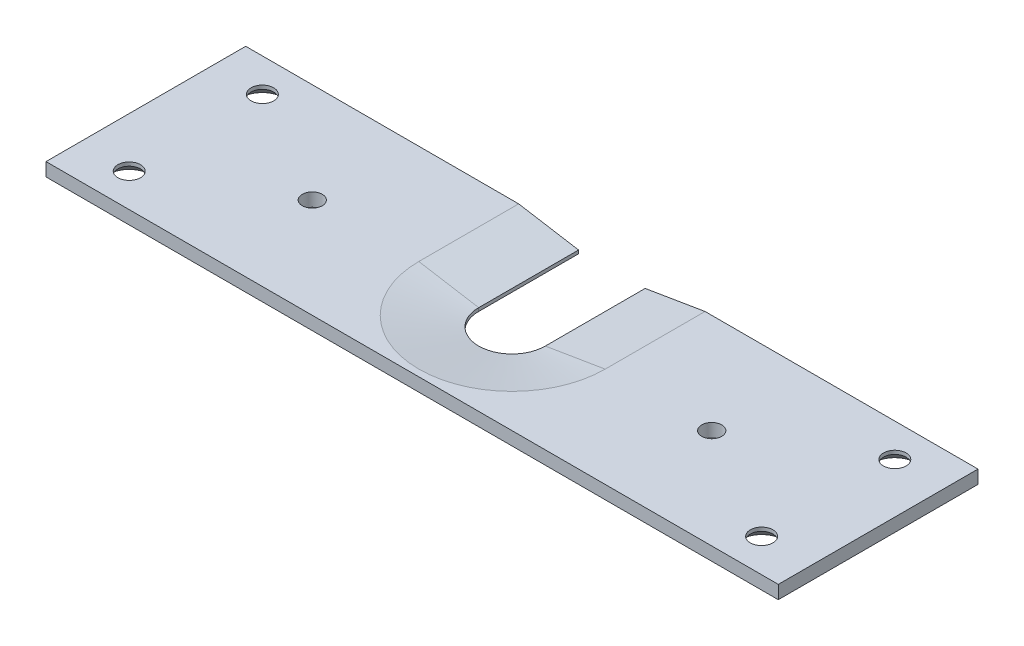
from build123d import *

# Parameters (mm, degrees)
SKETCH1_W                                    = 110
SKETCH1_H                                    = 30
EXTRUDE1_DEPTH                               = 2
CUT_EXTRUDE1_DEPTH                           = 3
CHAMFER1_SIZE                                = 9
CHAMFER1_SIZE2                               = 1.5
CSK_FOR_M3_COUNTERSUNK_RAISED_HEAD_S_2_COUNT = 2
CSK_FOR_M3_COUNTERSUNK_RAISED_HEAD_S_2_PITCH = 95
CSK_FOR_M3_COUNTERSUNK_RAISED_HEAD_S_3_COUNT = 2
CSK_FOR_M3_COUNTERSUNK_RAISED_HEAD_S_3_PITCH = 97.082439195
CSK_FOR_M3_COUNTERSUNK_RAISED_HEAD_S_4_COUNT = 2
CSK_FOR_M3_COUNTERSUNK_RAISED_HEAD_S_4_PITCH = 20
M3_TAPPED_HOLE1_D                            = 3


with BuildPart() as part:
    # Sketch1 → Extrude1 (new body)
    with BuildSketch(Plane(origin=(0, 0, 0), x_dir=(1, 0, 0), z_dir=(0, 1, 0))):
        Rectangle(SKETCH1_W, SKETCH1_H)
    extrude(amount=EXTRUDE1_DEPTH)

    # Sketch2 → Cut-Extrude1 (cut, through all)
    with BuildSketch(Plane(origin=(0, 2, 0), x_dir=(-1, 0, 0), z_dir=(0, 1, 0))):
        with BuildLine():
            Line((5, 0), (5, -15))
            Line((5, -15), (-5, -15))
            Line((-5, -15), (-5, 0))
            ThreePointArc((-5, 0), (0, 5), (5, 0))
        make_face()
    extrude(amount=-CUT_EXTRUDE1_DEPTH, mode=Mode.SUBTRACT)

    # Chamfer1
    chamfer1_edges = [part.edges().sort_by_distance(p)[0] for p in [
        (0, 2, 5),
        (5, 2, -7.5),
        (-5, 2, -7.5),
    ]]
    chamfer1_side = [part.faces().sort_by_distance(p)[0] for p in [
        (-53.859824575, 2, 0),
    ]]
    chamfer(chamfer1_edges, length=CHAMFER1_SIZE, length2=CHAMFER1_SIZE2, reference=chamfer1_side[0])

    # Sketch8 → CSK for M3 Countersunk Raised Head Screw1 (revolve, cut)
    with BuildSketch(Plane(origin=(47.5, 0, -10), x_dir=(0, 0, -1), z_dir=(1, 0, 0))):
        Polygon((0, 0), (0, 2), (1.7, 2), (1.7, 1.45), (3.15, 0), align=None)
    csk_for_m3_countersunk_raised_head_screw = revolve(axis=Axis((47.5, -6.35, -10), (0, 1, 0)), mode=Mode.SUBTRACT)

    # CSK for M3 Countersunk Raised Head S 2: CSK for M3 Countersunk Raised Head Screw1 ×2
    with Locations(*[(-i * CSK_FOR_M3_COUNTERSUNK_RAISED_HEAD_S_2_PITCH, 0, 0) for i in range(1, CSK_FOR_M3_COUNTERSUNK_RAISED_HEAD_S_2_COUNT)]):
        add(csk_for_m3_countersunk_raised_head_screw, mode=Mode.SUBTRACT)

    # CSK for M3 Countersunk Raised Head S 3: CSK for M3 Countersunk Raised Head Screw1 ×2
    with Locations(*[Vector(-0.978549785, 0, 0.206010481) * (i * CSK_FOR_M3_COUNTERSUNK_RAISED_HEAD_S_3_PITCH) for i in range(1, CSK_FOR_M3_COUNTERSUNK_RAISED_HEAD_S_3_COUNT)]):
        add(csk_for_m3_countersunk_raised_head_screw, mode=Mode.SUBTRACT)

    # CSK for M3 Countersunk Raised Head S 4: CSK for M3 Countersunk Raised Head Screw1 ×2
    with Locations(*[(0, 0, i * CSK_FOR_M3_COUNTERSUNK_RAISED_HEAD_S_4_PITCH) for i in range(1, CSK_FOR_M3_COUNTERSUNK_RAISED_HEAD_S_4_COUNT)]):
        add(csk_for_m3_countersunk_raised_head_screw, mode=Mode.SUBTRACT)

    # M3 Tapped Hole1 (through all)
    with Locations(Plane(origin=(0, 2, 0), x_dir=(-1, 0, 0), z_dir=(0, 1, 0))):
        with Locations((-30, 0), (30, 0)):
            Hole(M3_TAPPED_HOLE1_D / 2)


solid = part.part
